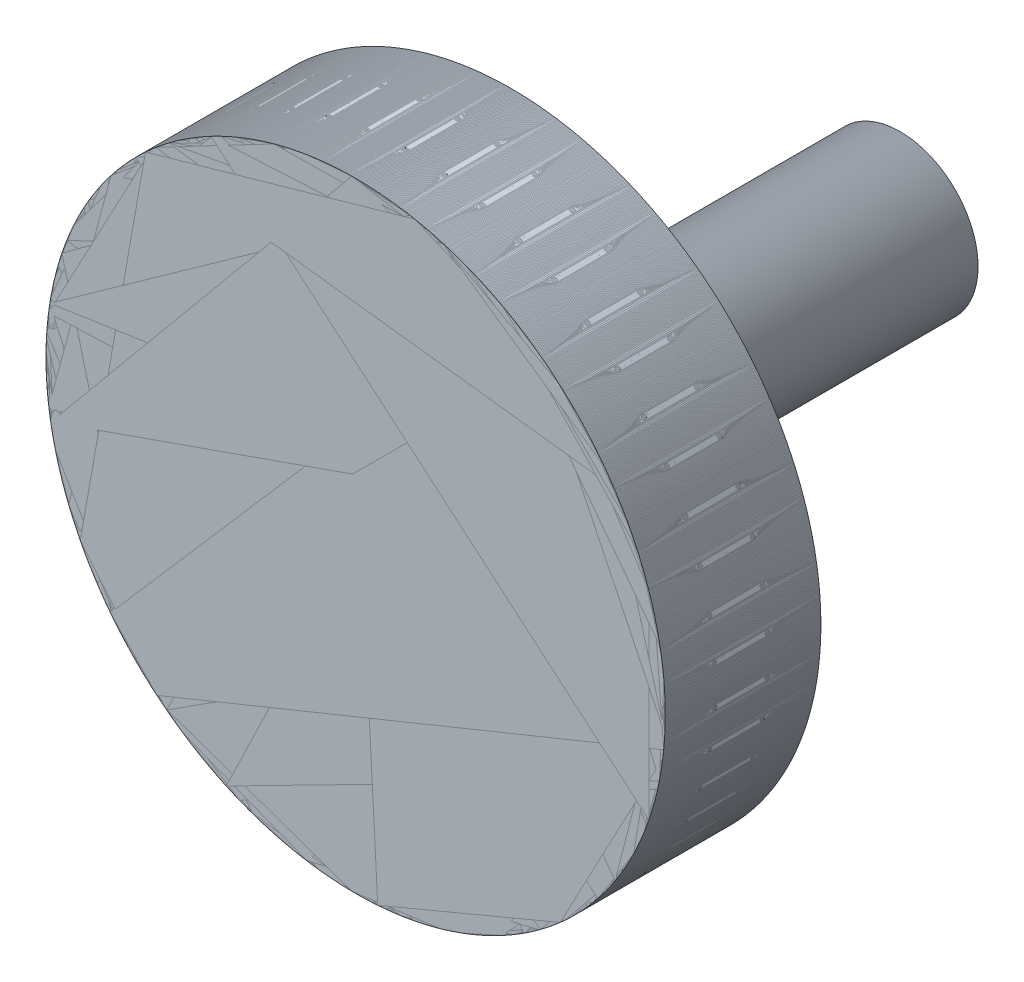
from build123d import *

# Parameters (mm, degrees)
SKETCH_1_R               = 99.5
EXTRUDE_1_DEPTH          = 5
SKETCH_2_R               = 99.5
SKETCH_2_R_2             = 97.5
EXTRUDE_3_DEPTH          = 40
SKETCH_3_R               = 99.5
EXTRUDE_4_DEPTH          = 5
SKETCH_4_R               = 25
EXTRUDE_5_DEPTH          = 125
SKETCH_5_R               = 22
CUT_EXTRUDE_1_DEPTH      = 135
SKETCH_6_R               = 0.75
CUT_EXTRUDE_3_DEPTH      = 100.5
CUT_EXTRUDE_3_DEPTH_BACK = 100.5
PATTERN_CIRCULAR_1_COUNT = 25
FILLET_1_R               = 5


with BuildPart() as part:
    # Эскиз1 → Бобышка-Вытянуть1 (new body)
    with BuildSketch(Plane.XY):
        Circle(SKETCH_1_R)
    extrude(amount=EXTRUDE_1_DEPTH)

    # Эскиз2 → Бобышка-Вытянуть3 (add)
    with BuildSketch(Plane.XY.offset(5)):
        Circle(SKETCH_2_R)
        Circle(SKETCH_2_R_2, mode=Mode.SUBTRACT)
    extrude(amount=EXTRUDE_3_DEPTH)

    # Эскиз3 → Бобышка-Вытянуть4 (add)
    with BuildSketch(Plane.XY.offset(45)):
        Circle(SKETCH_3_R)
    extrude(amount=EXTRUDE_4_DEPTH)

    # Эскиз4 → Бобышка-Вытянуть5 (add)
    with BuildSketch(Plane(origin=(0, 0, 0), x_dir=(-1, 0, 0), z_dir=(0, 0, -1))):
        Circle(SKETCH_4_R)
    extrude(amount=EXTRUDE_5_DEPTH)

    # Эскиз5 → Вырез-Вытянуть1 (cut)
    with BuildSketch(Plane(origin=(0, 0, -125), x_dir=(-1, 0, 0), z_dir=(0, 0, -1))):
        Circle(SKETCH_5_R)
    extrude(amount=-CUT_EXTRUDE_1_DEPTH, mode=Mode.SUBTRACT)

    # Эскиз6 → Вырез-Вытянуть3 (cut, two sides)
    with BuildSketch(Plane(origin=(0, 0, 0), x_dir=(1, 0, 0), z_dir=(0, 1, 0))) as cut_extrude_3_sk:
        with Locations(Location((0, -17, 0), (0, 0, 270))):  # turned: the seam where the file's is
            Circle(SKETCH_6_R)
        with Locations(Location((0, -34, 0), (0, 0, 270))):  # turned: the seam where the file's is
            Circle(SKETCH_6_R)
    extrude(amount=CUT_EXTRUDE_3_DEPTH, mode=Mode.SUBTRACT)
    extrude(cut_extrude_3_sk.sketch, amount=-CUT_EXTRUDE_3_DEPTH_BACK, mode=Mode.SUBTRACT)


with BuildPart() as pattern_circular_1_1:
    # Круговой массив1: pattern copy
    add(part.part.rotate(Axis((0, 0, 0), (0, 0, 1)), 1 * 360 / PATTERN_CIRCULAR_1_COUNT))


with BuildPart() as pattern_circular_1_2:
    # Круговой массив1: pattern copy
    add(part.part.rotate(Axis((0, 0, 0), (0, 0, 1)), 2 * 360 / PATTERN_CIRCULAR_1_COUNT))


with BuildPart() as pattern_circular_1_3:
    # Круговой массив1: pattern copy
    add(part.part.rotate(Axis((0, 0, 0), (0, 0, 1)), 3 * 360 / PATTERN_CIRCULAR_1_COUNT))


with BuildPart() as pattern_circular_1_4:
    # Круговой массив1: pattern copy
    add(part.part.rotate(Axis((0, 0, 0), (0, 0, 1)), 4 * 360 / PATTERN_CIRCULAR_1_COUNT))


with BuildPart() as pattern_circular_1_5:
    # Круговой массив1: pattern copy
    add(part.part.rotate(Axis((0, 0, 0), (0, 0, 1)), 5 * 360 / PATTERN_CIRCULAR_1_COUNT))


with BuildPart() as pattern_circular_1_6:
    # Круговой массив1: pattern copy
    add(part.part.rotate(Axis((0, 0, 0), (0, 0, 1)), 6 * 360 / PATTERN_CIRCULAR_1_COUNT))


with BuildPart() as pattern_circular_1_7:
    # Круговой массив1: pattern copy
    add(part.part.rotate(Axis((0, 0, 0), (0, 0, 1)), 7 * 360 / PATTERN_CIRCULAR_1_COUNT))


with BuildPart() as pattern_circular_1_8:
    # Круговой массив1: pattern copy
    add(part.part.rotate(Axis((0, 0, 0), (0, 0, 1)), 8 * 360 / PATTERN_CIRCULAR_1_COUNT))


with BuildPart() as pattern_circular_1_9:
    # Круговой массив1: pattern copy
    add(part.part.rotate(Axis((0, 0, 0), (0, 0, 1)), 9 * 360 / PATTERN_CIRCULAR_1_COUNT))


with BuildPart() as pattern_circular_1_10:
    # Круговой массив1: pattern copy
    add(part.part.rotate(Axis((0, 0, 0), (0, 0, 1)), 10 * 360 / PATTERN_CIRCULAR_1_COUNT))


with BuildPart() as pattern_circular_1_11:
    # Круговой массив1: pattern copy
    add(part.part.rotate(Axis((0, 0, 0), (0, 0, 1)), 11 * 360 / PATTERN_CIRCULAR_1_COUNT))


with BuildPart() as pattern_circular_1_12:
    # Круговой массив1: pattern copy
    add(part.part.rotate(Axis((0, 0, 0), (0, 0, 1)), 12 * 360 / PATTERN_CIRCULAR_1_COUNT))


with BuildPart() as pattern_circular_1_13:
    # Круговой массив1: pattern copy
    add(part.part.rotate(Axis((0, 0, 0), (0, 0, 1)), 13 * 360 / PATTERN_CIRCULAR_1_COUNT))


with BuildPart() as pattern_circular_1_14:
    # Круговой массив1: pattern copy
    add(part.part.rotate(Axis((0, 0, 0), (0, 0, 1)), 14 * 360 / PATTERN_CIRCULAR_1_COUNT))


with BuildPart() as pattern_circular_1_15:
    # Круговой массив1: pattern copy
    add(part.part.rotate(Axis((0, 0, 0), (0, 0, 1)), 15 * 360 / PATTERN_CIRCULAR_1_COUNT))


with BuildPart() as pattern_circular_1_16:
    # Круговой массив1: pattern copy
    add(part.part.rotate(Axis((0, 0, 0), (0, 0, 1)), 16 * 360 / PATTERN_CIRCULAR_1_COUNT))


with BuildPart() as pattern_circular_1_17:
    # Круговой массив1: pattern copy
    add(part.part.rotate(Axis((0, 0, 0), (0, 0, 1)), 17 * 360 / PATTERN_CIRCULAR_1_COUNT))


with BuildPart() as pattern_circular_1_18:
    # Круговой массив1: pattern copy
    add(part.part.rotate(Axis((0, 0, 0), (0, 0, 1)), 18 * 360 / PATTERN_CIRCULAR_1_COUNT))


with BuildPart() as pattern_circular_1_19:
    # Круговой массив1: pattern copy
    add(part.part.rotate(Axis((0, 0, 0), (0, 0, 1)), 19 * 360 / PATTERN_CIRCULAR_1_COUNT))


with BuildPart() as pattern_circular_1_20:
    # Круговой массив1: pattern copy
    add(part.part.rotate(Axis((0, 0, 0), (0, 0, 1)), 20 * 360 / PATTERN_CIRCULAR_1_COUNT))


with BuildPart() as pattern_circular_1_21:
    # Круговой массив1: pattern copy
    add(part.part.rotate(Axis((0, 0, 0), (0, 0, 1)), 21 * 360 / PATTERN_CIRCULAR_1_COUNT))


with BuildPart() as pattern_circular_1_22:
    # Круговой массив1: pattern copy
    add(part.part.rotate(Axis((0, 0, 0), (0, 0, 1)), 22 * 360 / PATTERN_CIRCULAR_1_COUNT))


with BuildPart() as pattern_circular_1_23:
    # Круговой массив1: pattern copy
    add(part.part.rotate(Axis((0, 0, 0), (0, 0, 1)), 23 * 360 / PATTERN_CIRCULAR_1_COUNT))


with BuildPart() as pattern_circular_1_24:
    # Круговой массив1: pattern copy
    add(part.part.rotate(Axis((0, 0, 0), (0, 0, 1)), 24 * 360 / PATTERN_CIRCULAR_1_COUNT))


with BuildPart() as part_1:
    add(part.part)

    # Скругление1
    fillet_1_edges = [part_1.edges().sort_by_distance(p)[0] for p in [
        (25, 0, 0),
    ]]
    fillet(fillet_1_edges, radius=FILLET_1_R)


solid = Compound([pattern_circular_1_1.part, pattern_circular_1_2.part, pattern_circular_1_3.part, pattern_circular_1_4.part, pattern_circular_1_5.part, pattern_circular_1_6.part, pattern_circular_1_7.part, pattern_circular_1_8.part, pattern_circular_1_9.part, pattern_circular_1_10.part, pattern_circular_1_11.part, pattern_circular_1_12.part, pattern_circular_1_13.part, pattern_circular_1_14.part, pattern_circular_1_15.part, pattern_circular_1_16.part, pattern_circular_1_17.part, pattern_circular_1_18.part, pattern_circular_1_19.part, pattern_circular_1_20.part, pattern_circular_1_21.part, pattern_circular_1_22.part, pattern_circular_1_23.part, pattern_circular_1_24.part, part_1.part])
